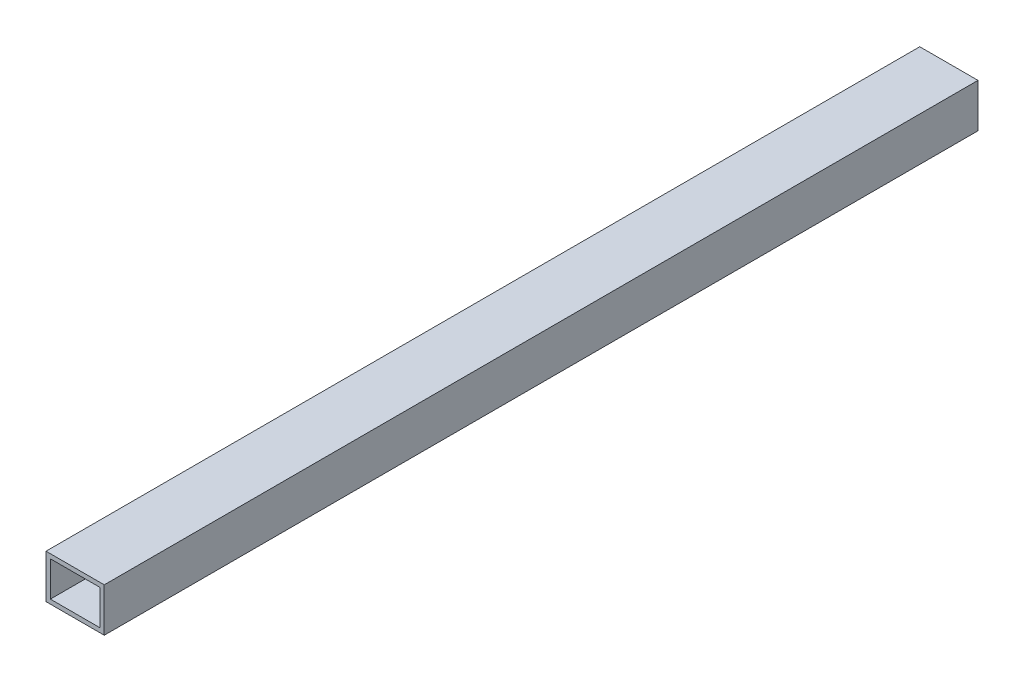
from build123d import *

# Parameters (mm, degrees)
CROQUIS1_W              = 600
CROQUIS1_H              = 30
SALIENTE_EXTRUIR1_DEPTH = 40
CROQUIS2_W              = 34
CROQUIS2_H              = 24
CORTAR_EXTRUIR1_DEPTH   = 890


with BuildPart() as part:
    # Croquis1 → Saliente-Extruir1 (new body)
    with BuildSketch(Plane(origin=(0, 0, 0), x_dir=(0, 0, -1), z_dir=(1, 0, 0))):
        Rectangle(CROQUIS1_W, CROQUIS1_H)
    extrude(amount=SALIENTE_EXTRUIR1_DEPTH)

    # Croquis2 → Cortar-Extruir1 (cut)
    with BuildSketch(Plane.XY.offset(300)):
        with Locations((20, 0)):
            Rectangle(CROQUIS2_W, CROQUIS2_H)
    extrude(amount=-CORTAR_EXTRUIR1_DEPTH, mode=Mode.SUBTRACT)


solid = part.part
